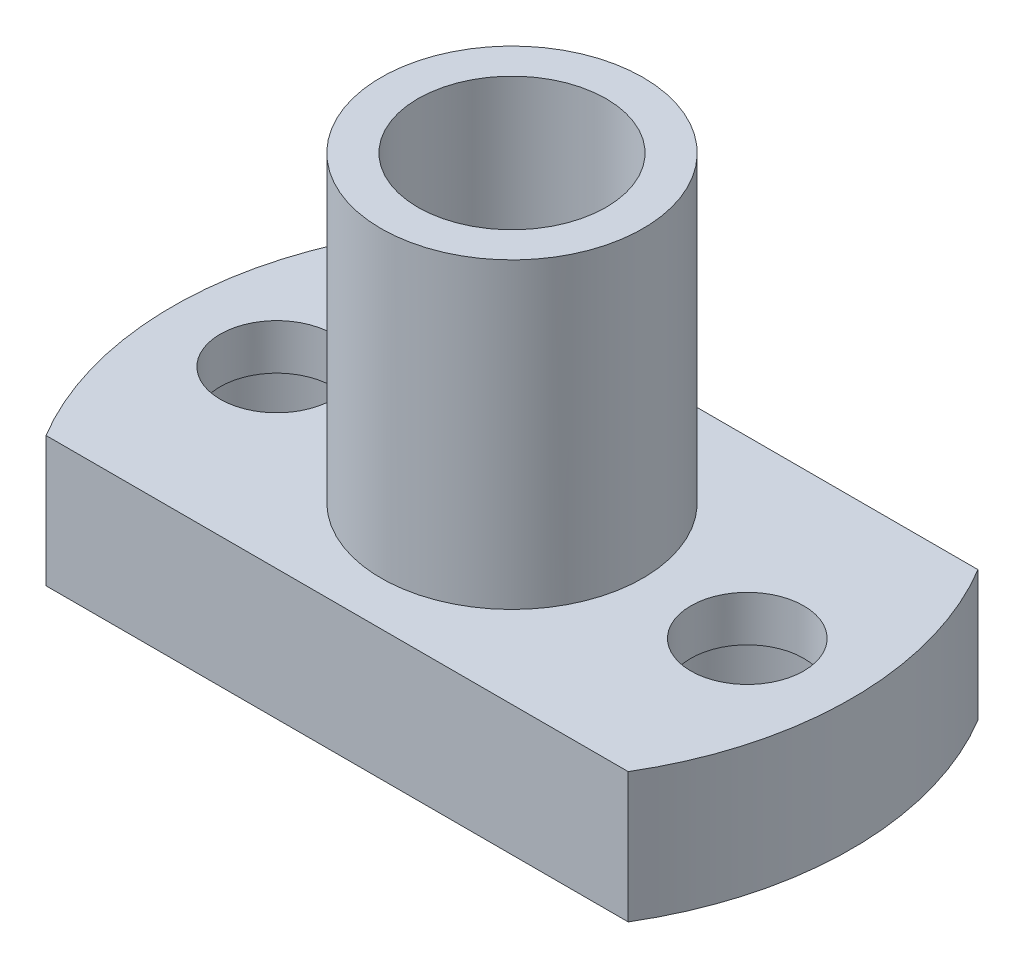
from build123d import *

# Parameters (mm, degrees)
SKETCH1_R           = 1.8
SKETCH1_R_2         = 3
BOSS_EXTRUDE1_DEPTH = 4.15
SKETCH2_R           = 4.175
SKETCH2_R_2         = 3
BOSS_EXTRUDE2_DEPTH = 9.65
SKETCH3_R           = 3
CUT_EXTRUDE1_DEPTH  = 2.7


with BuildPart() as part:
    # Sketch1 → Boss-Extrude1 (new body)
    with BuildSketch(Plane(origin=(0, 0, 0), x_dir=(1, 0, 0), z_dir=(0, 1, 0))):
        with BuildLine():
            Line((-9.279008568, -5.575), (9.279008568, -5.575))
            ThreePointArc((9.279008568, -5.575), (10.825, 0), (9.279008568, 5.575))
            Line((9.279008568, 5.575), (-9.279008568, 5.575))
            ThreePointArc((-9.279008568, 5.575), (-10.825, 0), (-9.279008568, -5.575))
        make_face()
        with Locations((-7.5, 0)):
            Circle(SKETCH1_R, mode=Mode.SUBTRACT)
        with Locations((7.5, 0)):
            Circle(SKETCH1_R, mode=Mode.SUBTRACT)
        Circle(SKETCH1_R_2, mode=Mode.SUBTRACT)
    extrude(amount=BOSS_EXTRUDE1_DEPTH)

    # Sketch2 → Boss-Extrude2 (add)
    with BuildSketch(Plane(origin=(0, 4.15, 0), x_dir=(1, 0, 0), z_dir=(0, 1, 0))):
        Circle(SKETCH2_R)
        Circle(SKETCH2_R_2, mode=Mode.SUBTRACT)
    extrude(amount=BOSS_EXTRUDE2_DEPTH)

    # Sketch3 → Cut-Extrude1 (cut)
    with BuildSketch(Plane.XZ):
        with Locations((7.5, 0)):
            Circle(SKETCH3_R)
        with Locations((-7.5, 0)):
            Circle(SKETCH3_R)
    extrude(amount=-CUT_EXTRUDE1_DEPTH, mode=Mode.SUBTRACT)


solid = part.part
